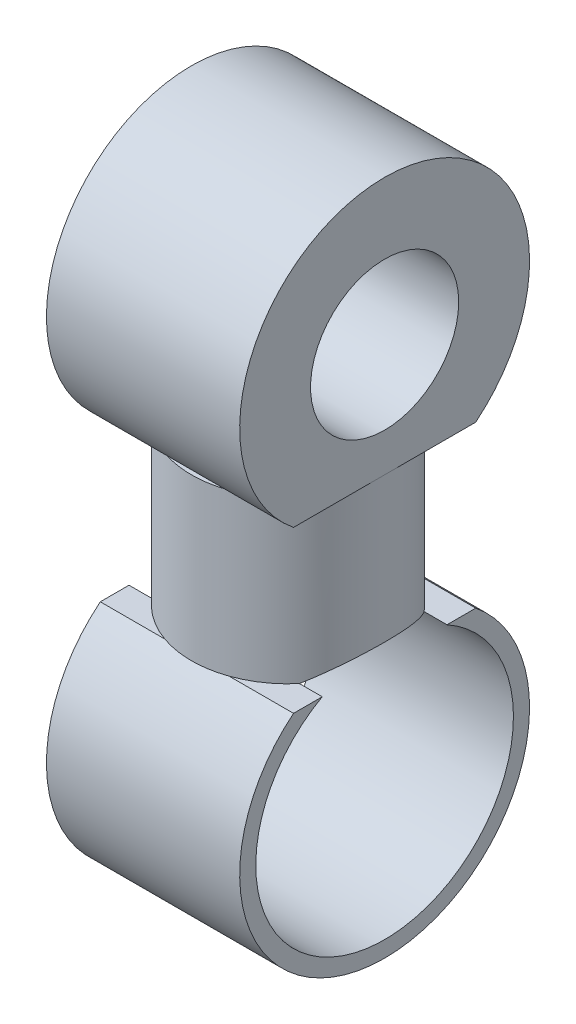
from build123d import *

# Parameters (mm, degrees)
SKETCH1_R            = 3
CRANK_BODY_DEPTH     = 4.5
PIN_SHAFT_BODY_DEPTH = 3
SKETCH4_R            = 2.3
PIN_SHAFT_DEPTH      = 16.00833102
SKETCH1_2_OUTSIDE_W  = 11.382
SKETCH1_2_OUTSIDE_H  = 14.382
SKETCH1_2_OUTSIDE_R  = 3
SMOOTHING_CUTS_DEPTH = 5
SKETCH5_R            = 4
CUT_EXTRUDE1_DEPTH   = 16.00833102


with BuildPart() as part:
    # Sketch1 → crank_body (new body)
    with BuildSketch(Plane(origin=(0, 0, 0), x_dir=(1, 0, 0), z_dir=(0, 1, 0))):
        Circle(SKETCH1_R)
    extrude(amount=CRANK_BODY_DEPTH)

    # Sketch3 → pin_shaft_body (add, symmetric)
    with BuildSketch(Plane(origin=(0, 0, 0), x_dir=(0, 0, -1), z_dir=(1, 0, 0))):
        with BuildLine():
            Line((-3, 5), (-3, 4.5))
            Line((-3, 4.5), (3, 4.5))
            Line((3, 4.5), (3, 5))
            Line((3, 5), (2.828427125, 5))
            ThreePointArc((2.828427125, 5), (0, 13), (-2.828427125, 5))
            Line((-2.828427125, 5), (-3, 5))
        make_face()
    pin_shaft_body = extrude(amount=PIN_SHAFT_BODY_DEPTH, both=True)

    # Sketch4 → pin_shaft (cut, through all)
    with BuildSketch(Plane(origin=(3, 0, 0), x_dir=(0, 0, -1), z_dir=(1, 0, 0))):
        with Locations((0, 8.5)):
            Circle(SKETCH4_R)
    extrude(amount=-PIN_SHAFT_DEPTH, mode=Mode.SUBTRACT)

    # Sketch1_2 outside → smoothing_cuts (cut)
    with BuildSketch(Plane(origin=(0, 0, 0), x_dir=(1, 0, 0), z_dir=(0, 1, 0))):
        Rectangle(SKETCH1_2_OUTSIDE_W, SKETCH1_2_OUTSIDE_H)
        Circle(SKETCH1_2_OUTSIDE_R, mode=Mode.SUBTRACT)
    smoothing_cuts = extrude(amount=SMOOTHING_CUTS_DEPTH, mode=Mode.SUBTRACT)

    # Mirror1: pin_shaft_body, smoothing_cuts across plane
    add(pin_shaft_body.mirror(Plane(origin=(0, 2.5, 0), x_dir=(0, 0, 1), z_dir=(0, -1, 0))))
    add(smoothing_cuts.mirror(Plane(origin=(0, 2.5, 0), x_dir=(0, 0, 1), z_dir=(0, -1, 0))), mode=Mode.SUBTRACT)

    # Sketch5 → Cut-Extrude1 (cut, through all)
    with BuildSketch(Plane(origin=(3, 0, 0), x_dir=(0, 0, -1), z_dir=(1, 0, 0))):
        with Locations((0, -3.5)):
            Circle(SKETCH5_R)
    extrude(amount=-CUT_EXTRUDE1_DEPTH, mode=Mode.SUBTRACT)


solid = part.part
